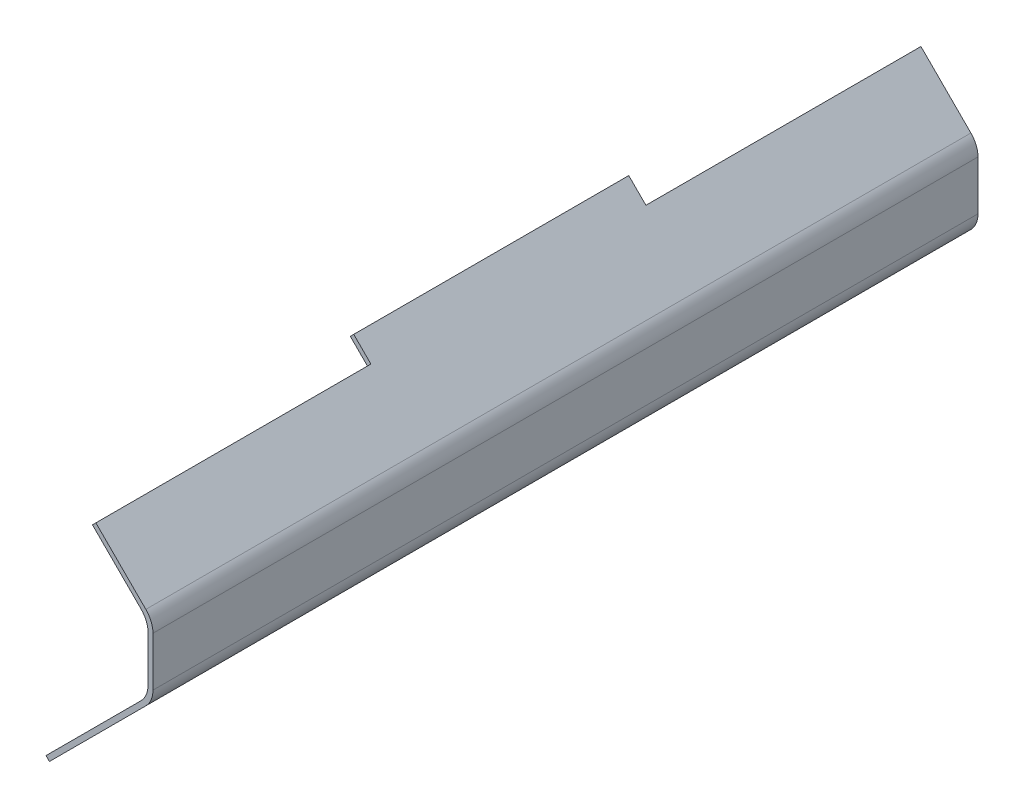
from build123d import *

# Parameters (mm, degrees)
BOSS_EXTRUDE1_DEPTH = 340
SKETCH4_W           = 113.333333333
SKETCH4_H           = 10
CUT_EXTRUDE3_DEPTH  = 24.627416998
SKETCH5_W           = 113.333333334
SKETCH5_H           = 10
CUT_EXTRUDE4_DEPTH  = 33.162950904
FILLET2_R           = 10


with BuildPart() as part:
    # Sketch1 → Boss-Extrude1 (new body)
    with BuildSketch(Plane.XY):
        Polygon((48.461940777, 43.461940777), (49.876154339, 44.876154339), (80.461940777, 14.290367902), (80.461940777, -14.290367902), (37.805086528, -56.947222151), (36.390872965, -55.533008589), (78.461940777, -13.461940777), (78.461940777, 13.461940777), align=None)
    extrude(amount=BOSS_EXTRUDE1_DEPTH)

    # Sketch4 → Cut-Extrude3 (cut, through all)
    with BuildSketch(Plane(origin=(45.961940777, 45.961940777, 0), x_dir=(0, 0, 1), z_dir=(-0.707106781, -0.707106781, 0))):
        with Locations((56.666666667, -8.535533906)):
            Rectangle(SKETCH4_W, SKETCH4_H)
        with Locations((283.333333334, -8.535533906)):
            Rectangle(SKETCH4_W, SKETCH4_H)
    extrude(amount=-CUT_EXTRUDE3_DEPTH, mode=Mode.SUBTRACT)

    # Sketch5 → Cut-Extrude4 (cut, through all)
    with BuildSketch(Plane(origin=(45.961940777, -45.961940777, 0), x_dir=(0, 0, 1), z_dir=(-0.707106781, 0.707106781, 0))):
        with Locations((170, -8.535533906)):
            Rectangle(SKETCH5_W, SKETCH5_H)
    extrude(amount=-CUT_EXTRUDE4_DEPTH, mode=Mode.SUBTRACT)

    # Fillet2
    fillet2_edges = [part.edges().sort_by_distance(p)[0] for p in [
        (80.461940777, 14.290367902, 170),
        (80.461940777, -14.290367902, 170),
        (78.461940777, -13.461940777, 170),
        (78.461940777, 13.461940777, 170),
    ]]
    fillet(fillet2_edges, radius=FILLET2_R)


solid = part.part
